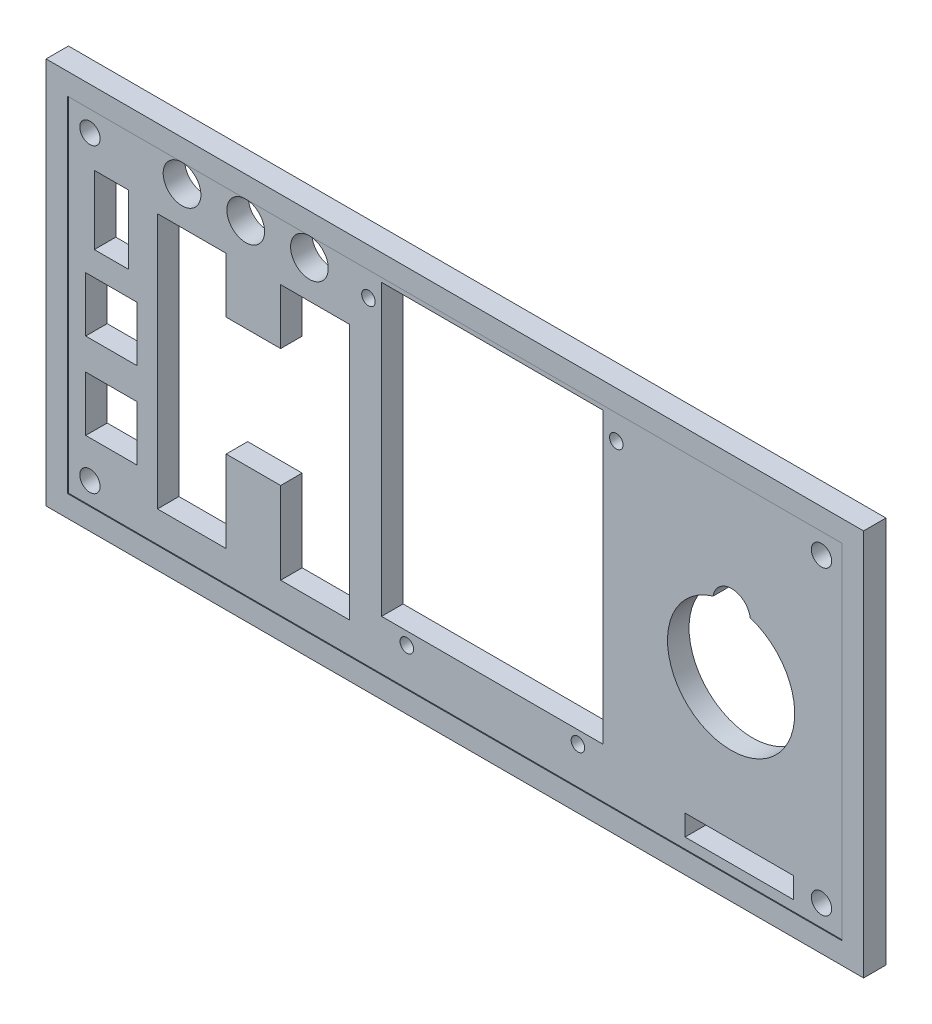
from build123d import *

# Parameters (mm, degrees)
MODEL_W             = 114.2864
MODEL_H             = 50.7864
MODEL_R             = 1.5
MODEL_W_2           = 7.5932
MODEL_H_2           = 8.1012
MODEL_R_2           = 1
MODEL_W_3           = 15.9766
MODEL_H_3           = 3.0734
MODEL_W_4           = 5.0528
MODEL_H_4           = 10.132799902
MODEL_R_3           = 2.7813
MODEL_W_5           = 32.6908
MODEL_H_5           = 42.6908
BOSS_EXTRUDE1_DEPTH = 3.175
SKETCH1_W           = 120.636394244
SKETCH1_H           = 57.136394614
SKETCH1_W_2         = 114.2864
SKETCH1_H_2         = 50.7864
BOSS_EXTRUDE2_DEPTH = 3.302


with BuildPart() as part:
    # Model → Boss-Extrude1 (new body)
    with BuildSketch(Plane.XY):
        with Locations((57.143197122, 25.393197307)):
            Rectangle(MODEL_W, MODEL_H)
        with Locations((3.175, 3.175)):
            Circle(MODEL_R, mode=Mode.SUBTRACT)
        with Locations((6.343197122, 12.693197307)):
            Rectangle(MODEL_W_2, MODEL_H_2, mode=Mode.SUBTRACT)
        with Locations((49.9364, 5.5118)):
            Circle(MODEL_R_2, mode=Mode.SUBTRACT)
        with Locations((6.343197122, 25.393197307)):
            Rectangle(MODEL_W_2, MODEL_H_2, mode=Mode.SUBTRACT)
        Polygon((23.272097122, 4.543497307), (13.137897122, 4.543497307), (13.137897122, 42.280497307), (23.272097122, 42.280497307), (23.272097122, 34.120497307), (31.314978679, 34.120497307), (31.314978679, 42.301497307), (41.449178679, 42.301497307), (41.449178679, 4.522497307), (31.314978679, 4.522497307), (31.314978679, 16.629297307), (23.272097122, 16.629297307), align=None, mode=Mode.SUBTRACT)
        with Locations((75.184, 5.5118)):
            Circle(MODEL_R_2, mode=Mode.SUBTRACT)
        with Locations((98.979297122, 3.0734)):
            Rectangle(MODEL_W_3, MODEL_H_3, mode=Mode.SUBTRACT)
        with Locations((111.125, 3.175)):
            Circle(MODEL_R, mode=Mode.SUBTRACT)
        with Locations((6.343197122, 38.093197307)):
            Rectangle(MODEL_W_4, MODEL_H_4, mode=Mode.SUBTRACT)
        with Locations((3.175, 47.625)):
            Circle(MODEL_R, mode=Mode.SUBTRACT)
        with Locations((16.764, 47.879)):
            Circle(MODEL_R_3, mode=Mode.SUBTRACT)
        with Locations((26.162, 47.879)):
            Circle(MODEL_R_3, mode=Mode.SUBTRACT)
        with Locations((35.56, 47.879)):
            Circle(MODEL_R_3, mode=Mode.SUBTRACT)
        with Locations((44.2722, 47.0662)):
            Circle(MODEL_R_2, mode=Mode.SUBTRACT)
        with Locations((62.553997122, 28.695197307)):
            Rectangle(MODEL_W_5, MODEL_H_5, mode=Mode.SUBTRACT)
        with BuildLine():
            ThreePointArc((100.60678971, 34.352628207), (105.35704277, 30.951911366), (107.1753, 25.4))
            ThreePointArc((107.1753, 25.4), (92.170948878, 17.88267863), (95.133038042, 34.401355967))
            ThreePointArc((95.133038042, 34.401355967), (97.890845314, 36.728290305), (100.60678971, 34.352628207))
        make_face(mode=Mode.SUBTRACT)
        with Locations((80.8482, 47.0662)):
            Circle(MODEL_R_2, mode=Mode.SUBTRACT)
        with Locations((111.125, 47.625)):
            Circle(MODEL_R, mode=Mode.SUBTRACT)
    extrude(amount=BOSS_EXTRUDE1_DEPTH)

    # Sketch1 → Boss-Extrude2 (add)
    with BuildSketch(Plane.XY):
        with Locations((57.143197122, 25.393197307)):
            Rectangle(SKETCH1_W, SKETCH1_H)
        with Locations((57.143197122, 25.393197307)):
            Rectangle(SKETCH1_W_2, SKETCH1_H_2, mode=Mode.SUBTRACT)
    extrude(amount=BOSS_EXTRUDE2_DEPTH)


solid = part.part
